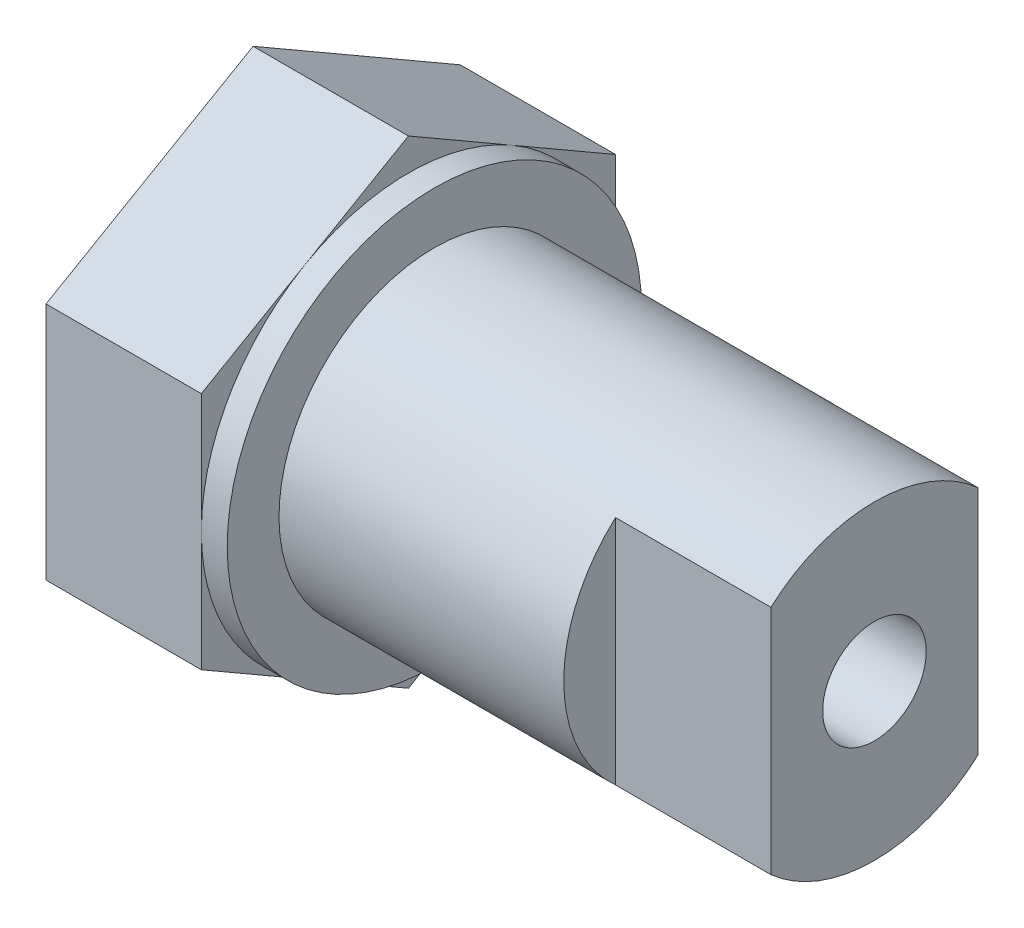
from build123d import *

# Parameters (mm, degrees)
BOSS_EXTRUDE1_DEPTH = 38.1
BOSS_EXTRUDE2_DEPTH = 6.35
SKETCH2_R           = 38.1
BOSS_EXTRUDE3_DEPTH = 107.95
SKETCH3_R           = 12.7
CUT_EXTRUDE1_DEPTH  = 172.018283623
CUT_EXTRUDE2_START  = -38.1
CUT_EXTRUDE2_DEPTH  = 38.1


with BuildPart() as part:
    # Sketch1 → Boss-Extrude1 (new body)
    with BuildSketch(Plane(origin=(0, 0, 0), x_dir=(0, 0, -1), z_dir=(1, 0, 0))):
        Polygon((50.8, 29.329393675), (0, 58.65878735), (-50.8, 29.329393675), (-50.8, -29.329393675), (0, -58.65878735), (50.8, -29.329393675), align=None)
    extrude(amount=-BOSS_EXTRUDE1_DEPTH)

    # Sketch1_3 → Boss-Extrude2 (add)
    with BuildSketch(Plane(origin=(0, 0, 0), x_dir=(0, 0, -1), z_dir=(1, 0, 0))):
        with BuildLine():
            ThreePointArc((50.8, 0), (43.994090583, 25.399999877), (25.400000247, 43.99409037))
            ThreePointArc((25.400000247, 43.99409037), (3.52e-07, 50.8), (-25.399999637, 43.994090722))
            ThreePointArc((-25.399999637, 43.994090722), (-43.994090395, 25.400000202), (-50.8, 4.8e-08))
            ThreePointArc((-50.8, 4.8e-08), (-43.994090651, -25.399999759), (-25.400000441, -43.994090258))
            ThreePointArc((-25.400000441, -43.994090258), (-2.2e-07, -50.8), (25.400000059, -43.994090478))
            ThreePointArc((25.400000059, -43.994090478), (43.994090529, -25.39999997), (50.8, 0))
        make_face()
    extrude(amount=BOSS_EXTRUDE2_DEPTH)

    # Sketch2 → Boss-Extrude3 (add)
    with BuildSketch(Plane(origin=(6.35, 0, 0), x_dir=(0, 0, -1), z_dir=(1, 0, 0))):
        Circle(SKETCH2_R)
    extrude(amount=BOSS_EXTRUDE3_DEPTH)

    # Sketch3 → Cut-Extrude1 (cut, through all)
    with BuildSketch(Plane(origin=(114.3, 0, 0), x_dir=(0, 0, -1), z_dir=(1, 0, 0))):
        Circle(SKETCH3_R)
    extrude(amount=-CUT_EXTRUDE1_DEPTH, mode=Mode.SUBTRACT)

    # Sketch3_3 → Cut-Extrude2 (cut)
    with BuildSketch(Plane(origin=(114.3, 0, 0), x_dir=(0, 0, -1), z_dir=(1, 0, 0)).offset(CUT_EXTRUDE2_START)):
        with BuildLine():
            Line((-25.4, -28.398063314), (-25.4, 28.398063314))
            ThreePointArc((-25.4, 28.398063314), (-38.1, 0), (-25.4, -28.398063314))
        make_face()
        with BuildLine():
            ThreePointArc((25.4, -28.398063314), (38.1, 0), (25.4, 28.398063314))
            Line((25.4, 28.398063314), (25.4, -28.398063314))
        make_face()
    extrude(amount=CUT_EXTRUDE2_DEPTH, mode=Mode.SUBTRACT)


solid = part.part
